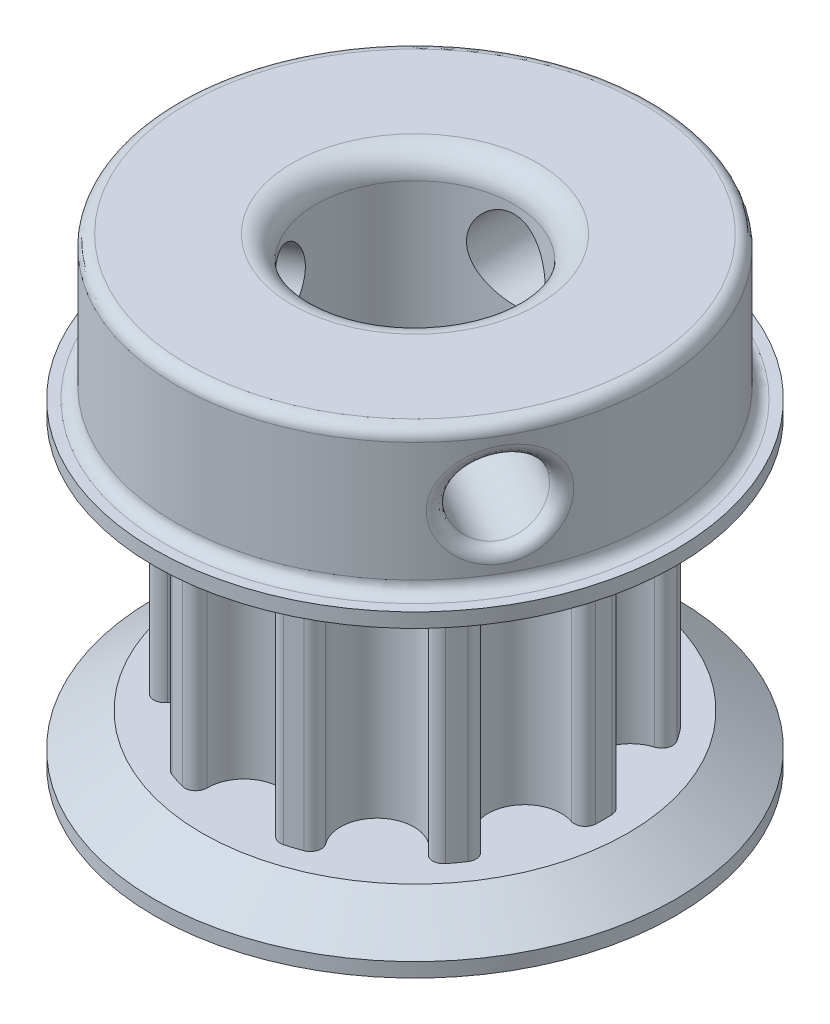
from build123d import *

# Parameters (mm, degrees)
BOSS_EXTRU_1_DEPTH           = 9.3
R_P_TITION_CIRCULAIRE1_COUNT = 10
ESQUISSE2_R                  = 10.925130477
BOSS_EXTRU_2_DEPTH           = 2
CHANFREIN1_SIZE              = 2
CHANFREIN1_SIZE2             = 1.400415076
CHANFREIN1_PART_2_SIZE       = 2
CHANFREIN1_PART_2_SIZE2      = 1.400415076
ESQUISSE4_R                  = 10
BOSS_EXTRU_3_DEPTH           = 6
ESQUISSE5_R                  = 1.65
ENL_V_MAT_EXTRU_2_DEPTH      = 11.925130477
R_P_TITION_CIRCULAIRE2_COUNT = 3
ENL_V_MAT_EXTRU_1_REACH      = 21.3
ESQUISSE3_R                  = 4.15
CONG_1_R                     = 1
CONG_2_R                     = 0.5


with BuildPart() as part:
    # Esquisse1 → Boss.-Extru.1 (new body)
    with BuildSketch(Plane(origin=(0, 0, 0), x_dir=(1, 0, 0), z_dir=(0, 1, 0))):
        with BuildLine():
            Line((0, 0), (-2.449, 7.537246983))
            ThreePointArc((-2.449, 7.537246983), (-2.286802769, 7.588031772), (-2.123553773, 7.635326611))
            ThreePointArc((-2.123553773, 7.635326611), (-1.721383845, 7.556942144), (-1.5428703, 7.188136381))
            ThreePointArc((-1.5428703, 7.188136381), (0, 5.625130477), (1.5428703, 7.188136381))
            ThreePointArc((1.5428703, 7.188136381), (1.721383845, 7.556942144), (2.123553773, 7.635326611))
            ThreePointArc((2.123553773, 7.635326611), (2.286802769, 7.588031772), (2.449, 7.537246983))
            Line((2.449, 7.537246983), (0, 0))
        make_face()
    boss_extru_1 = extrude(amount=BOSS_EXTRU_1_DEPTH)

    # Répétition circulaire1: Boss.-Extru.1 ×10 about axis
    r_p_tition_circulaire1_axis = Axis((0, 0, 0), (0, 1, 0))
    for i in range(1, R_P_TITION_CIRCULAIRE1_COUNT):
        add(boss_extru_1.rotate(r_p_tition_circulaire1_axis, i * 360 / R_P_TITION_CIRCULAIRE1_COUNT))

    # Esquisse2 → Boss.-Extru.2 (add)
    with BuildSketch(Plane(origin=(0, 9.3, 0), x_dir=(1, 0, 0), z_dir=(0, 1, 0))):
        Circle(ESQUISSE2_R)
    boss_extru_2 = extrude(amount=BOSS_EXTRU_2_DEPTH)

    # Symétrie1: Boss.-Extru.2 across plane
    add(boss_extru_2.mirror(Plane(origin=(0, 4.65, 0), x_dir=(0, 0, 1), z_dir=(0, -1, 0))))

    # Chanfrein1
    chanfrein1_edges = [part.edges().sort_by_distance(p)[0] for p in [
        (-10.925130477, 9.3, 0),
    ]]
    chanfrein1_side = [part.faces().sort_by_distance(p)[0] for p in [
        (-10.616121123, 9.3, 0),
    ]]
    chamfer(chanfrein1_edges, length=CHANFREIN1_SIZE, length2=CHANFREIN1_SIZE2, reference=chanfrein1_side[0])

    # Chanfrein1 part 2
    chanfrein1_part_2_edges = [part.edges().sort_by_distance(p)[0] for p in [
        (-10.925130477, 0, 0),
    ]]
    chanfrein1_part_2_side = [part.faces().sort_by_distance(p)[0] for p in [
        (-10.616121123, 0, 0),
    ]]
    chamfer(chanfrein1_part_2_edges, length=CHANFREIN1_PART_2_SIZE, length2=CHANFREIN1_PART_2_SIZE2, reference=chanfrein1_part_2_side[0])

    # Esquisse4 → Boss.-Extru.3 (add)
    with BuildSketch(Plane(origin=(0, 11.3, 0), x_dir=(1, 0, 0), z_dir=(0, 1, 0))):
        Circle(ESQUISSE4_R)
    extrude(amount=BOSS_EXTRU_3_DEPTH)

    # Esquisse5 → Enlèv. mat.-Extru.2 (cut, through all)
    with BuildSketch(Plane.XY):
        with Locations((0, 14.3)):
            Circle(ESQUISSE5_R)
    enl_v_mat_extru_2 = extrude(amount=-ENL_V_MAT_EXTRU_2_DEPTH, mode=Mode.SUBTRACT)

    # Répétition circulaire2: Enlèv. mat.-Extru.2 ×3 about axis
    r_p_tition_circulaire2_axis = Axis((0, 17.3, 0), (0, -1, 0))
    for i in range(1, R_P_TITION_CIRCULAIRE2_COUNT):
        add(enl_v_mat_extru_2.rotate(r_p_tition_circulaire2_axis, i * 360 / R_P_TITION_CIRCULAIRE2_COUNT), mode=Mode.SUBTRACT)

    # Esquisse3 → Enlèv. mat.-Extru.1 (cut, up to next)
    with BuildSketch(Plane(origin=(0, 17.3, 0), x_dir=(1, 0, 0), z_dir=(0, 1, 0)), mode=Mode.PRIVATE) as enl_v_mat_extru_1_sk1:
        Circle(ESQUISSE3_R)
    enl_v_mat_extru_1_tool1 = extrude(enl_v_mat_extru_1_sk1.sketch, amount=-ENL_V_MAT_EXTRU_1_REACH, mode=Mode.PRIVATE) & part.part
    add(enl_v_mat_extru_1_tool1.solids().sort_by_distance((0, 17.3, 0))[0], mode=Mode.SUBTRACT)

    # Congé1
    cong_1_edges = [part.edges().sort_by_distance(p)[0] for p in [
        (-4.15, -2, 0),
        (-4.15, 17.3, 0),
    ]]
    fillet(cong_1_edges, radius=CONG_1_R)

    # Congé2
    cong_2_edges = [part.edges().sort_by_distance(p)[0] for p in [
        (-10, 11.3, 0),
        (-10, 17.3, 0),
        (-1.650000023, 14.300000005, -9.862935666),
        (9.366552854, 14.300000005, 3.502525897),
        (-7.716552831, 14.300000005, 6.360409769),
    ]]
    fillet(cong_2_edges, radius=CONG_2_R)


solid = part.part
